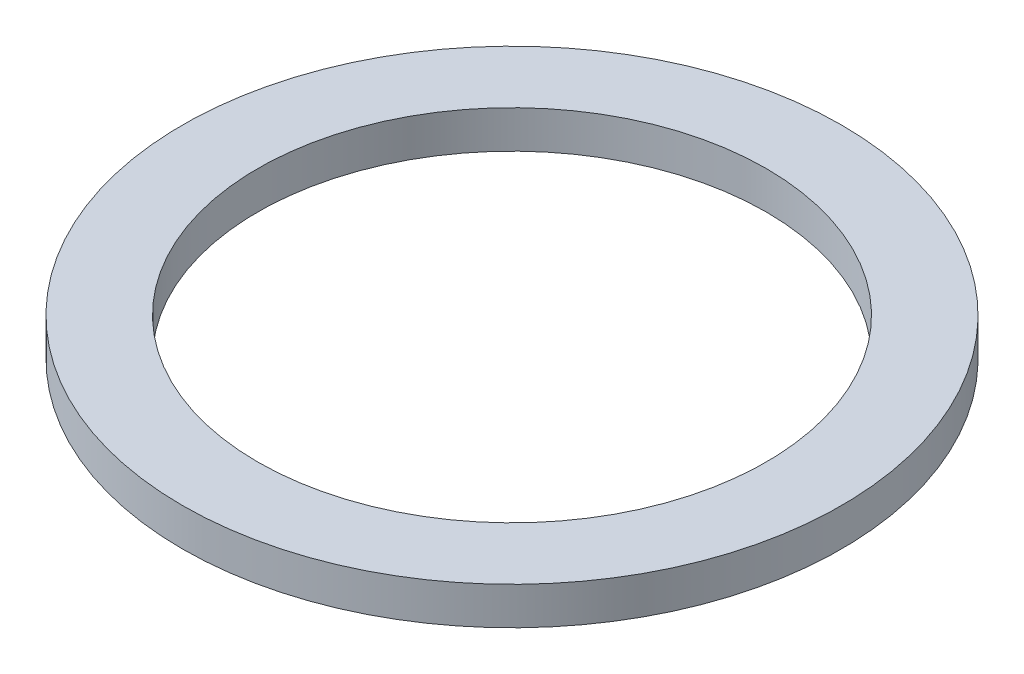
from build123d import *

# Parameters (mm, degrees)
SKETCH1_R           = 4.445
SKETCH1_R_2         = 3.429
BOSS_EXTRUDE1_DEPTH = 0.508


with BuildPart() as part:
    # Sketch1 → Boss-Extrude1 (new body)
    with BuildSketch(Plane(origin=(0, 0, 0), x_dir=(1, 0, 0), z_dir=(0, 1, 0))):
        Circle(SKETCH1_R)
        Circle(SKETCH1_R_2, mode=Mode.SUBTRACT)
    extrude(amount=BOSS_EXTRUDE1_DEPTH)


solid = part.part
